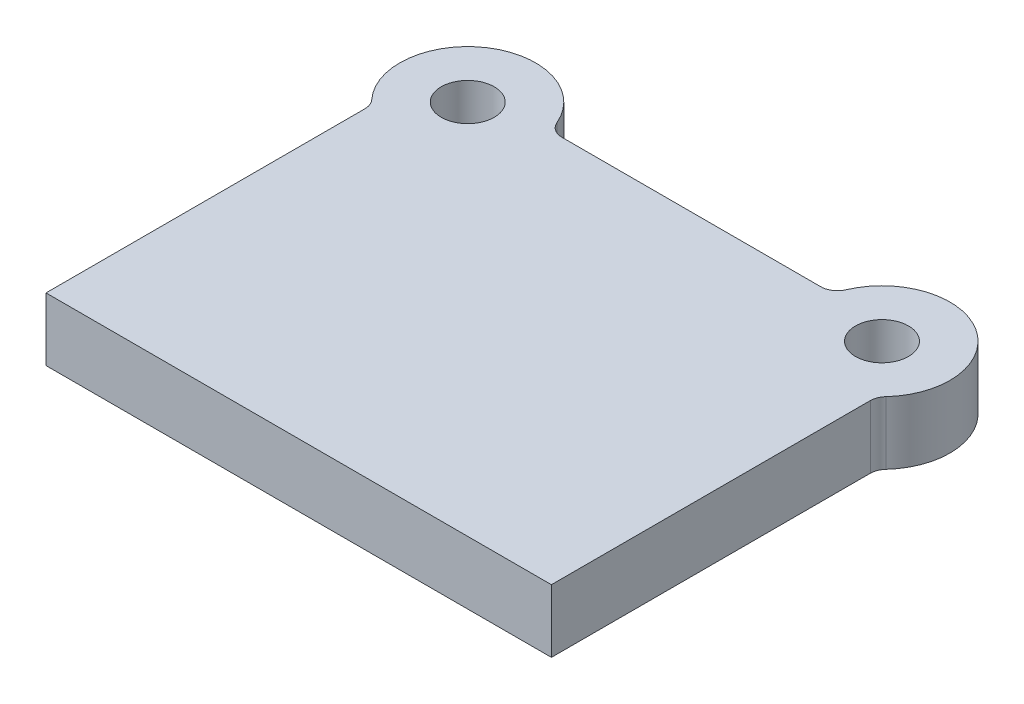
from build123d import *

# Parameters (mm, degrees)
SKETCH1_R           = 16
BOSS_EXTRUDE1_DEPTH = 38
FILLET2_R           = 10


with BuildPart() as part:
    # Sketch1 → Boss-Extrude1 (new body)
    with BuildSketch(Plane(origin=(0, 0, 0), x_dir=(1, 0, 0), z_dir=(0, 1, 0))):
        with BuildLine():
            Line((152.5, 0), (-152.5, 0))
            Line((-152.5, 0), (-152.5, 196.590297601))
            ThreePointArc((-152.5, 196.590297601), (-146.114542141, 262.145072346), (-85.238209296, 237))
            Line((-85.238209296, 237), (85.238209296, 237))
            ThreePointArc((85.238209296, 237), (146.114542141, 262.145072346), (152.5, 196.590297601))
            Line((152.5, 196.590297601), (152.5, 0))
        make_face()
        with Locations((-125, 227)):
            Circle(SKETCH1_R, mode=Mode.SUBTRACT)
        with Locations((125, 227)):
            Circle(SKETCH1_R, mode=Mode.SUBTRACT)
    extrude(amount=BOSS_EXTRUDE1_DEPTH)

    # Fillet2
    fillet2_edges = [part.edges().sort_by_distance(p)[0] for p in [
        (-152.5, 19, -196.590297601),
        (-85.238209296, 19, -237),
        (85.238209296, 19, -237),
        (152.5, 19, -196.590297601),
    ]]
    fillet(fillet2_edges, radius=FILLET2_R)


solid = part.part
